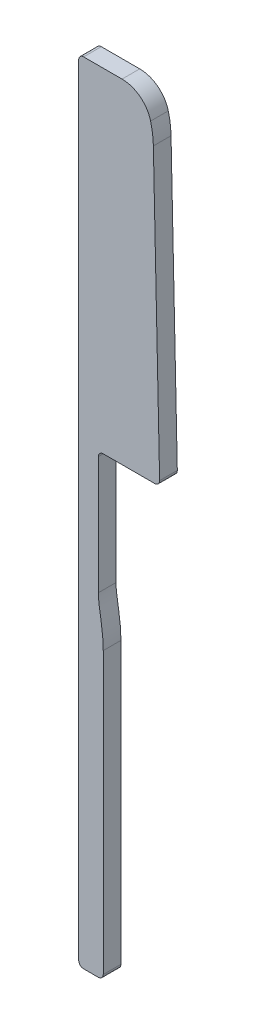
from build123d import *

# Parameters (mm, degrees)
BOSS_EXTRUDE1_DEPTH = 1.8
FILLET1_R           = 0.5
SKETCH2_R           = 1.75
BOSS_EXTRUDE3_DEPTH = 1.8
CUT_EXTRUDE2_DEPTH  = 1.8
FILLET2_R           = 0.5
FILLET3_R           = 3


with BuildPart() as part:
    # Sketch1 → Boss-Extrude1 (new body)
    with BuildSketch(Plane.XY):
        with BuildLine():
            Line((0, 4.5), (0, 6.5))
            Line((0, 6.5), (6, 6.5))
            Line((6, 6.5), (6, 10.5))
            Line((6, 10.5), (10, 14.5))
            Line((10, 14.5), (10, 83.5))
            Line((10, 83.5), (16.4, 83.5))
            ThreePointArc((16.4, 83.5), (17.2719581, 81.425344658), (17.601960582, 79.199226044))
            Line((17.601960582, 79.199226044), (18.25, 49.5))
            Line((18.25, 49.5), (12, 49.5))
            Line((12, 49.5), (12, 37))
            add(Edge.make_bspline(
                [(12, 37), (12, 35.742192932), (12.5, 34.153450807), (12.5, 32.15)],
                knots=[0, 0, 0, 0, 1, 1, 1, 1], degree=3))
            Line((12.5, 32.15), (12.5, 2.89))
            ThreePointArc((12.5, 2.89), (11.653538598, 0.846461402), (9.61, 0))
            ThreePointArc((9.61, 0), (4.304293167, 1.180712741), (0, 4.5))
        make_face()
    extrude(amount=BOSS_EXTRUDE1_DEPTH)

    # Fillet1
    fillet1_edges = [part.edges().sort_by_distance(p)[0] for p in [
        (0, 4.5, 0.9),
        (0, 6.5, 0.9),
        (6, 6.5, 0.9),
        (6, 10.5, 0.9),
        (10, 14.5, 0.9),
        (10, 83.5, 0.9),
        (18.25, 49.5, 0.9),
        (12, 49.5, 0.9),
    ]]
    fillet(fillet1_edges, radius=FILLET1_R)

    # Sketch2 → Boss-Extrude3 (add)
    with BuildSketch(Plane.XY):
        with BuildLine():
            Line((7, -2.499596966), (7, 0.500403034))
            Line((7, 0.500403034), (11, 0.500403034))
            Line((11, 0.500403034), (11.824045318, -1.578286292))
            ThreePointArc((11.824045318, -1.578286292), (9.968981185, -4.955214332), (7, -2.499596966))
        make_face()
        with Locations((9.5, -2.499596966)):
            Circle(SKETCH2_R, mode=Mode.SUBTRACT)
    extrude(amount=BOSS_EXTRUDE3_DEPTH)

    # Sketch5 → Cut-Extrude2 (cut)
    with BuildSketch(Plane.XY):
        Polygon((10, 29.542425494), (10, 3.09), (19.868157727, 3.09), (19.868157727, -10.013619472), (-11.195906999, -10.013619472), (-11.195906999, 29.542425494), align=None)
    extrude(amount=CUT_EXTRUDE2_DEPTH, mode=Mode.SUBTRACT)

    # Fillet2
    fillet2_edges = [part.edges().sort_by_distance(p)[0] for p in [
        (10, 3.09, 0.9),
        (12.5, 3.09, 0.9),
    ]]
    fillet(fillet2_edges, radius=FILLET2_R)

    # Fillet3
    fillet3_edges = [part.edges().sort_by_distance(p)[0] for p in [
        (16.4, 83.5, 0.9),
    ]]
    fillet(fillet3_edges, radius=FILLET3_R)


solid = part.part
